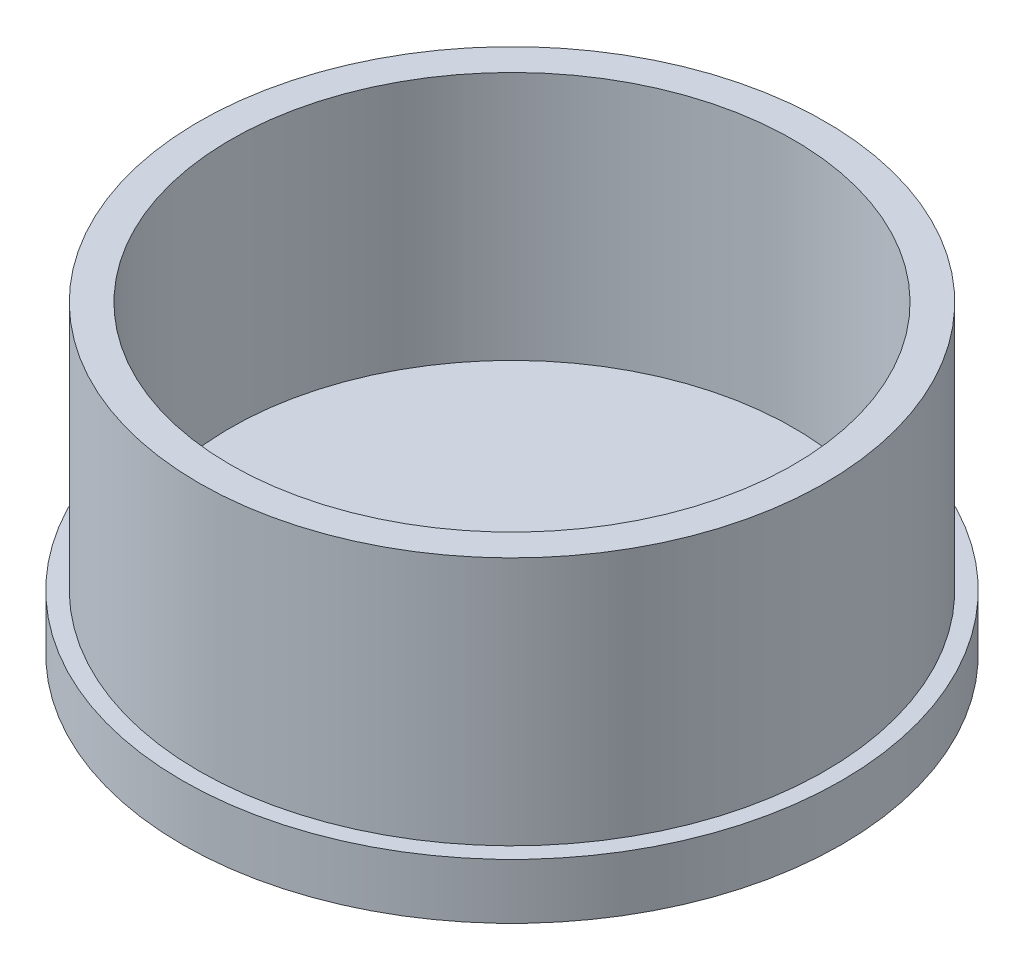
from build123d import *

# Parameters (mm, degrees)
ESBO_O1_R                = 59.5
RESSALTO_EXTRUS_O1_DEPTH = 55
ESBO_O2_R                = 50.8
CORTE_EXTRUS_O1_DEPTH    = 45
ESBO_O3_R                = 59.5
ESBO_O3_R_2              = 56.5
CORTE_EXTRUS_O2_DEPTH    = 45


with BuildPart() as part:
    # Esboço1 → Ressalto-extrusão1 (new body)
    with BuildSketch(Plane(origin=(0, 0, 0), x_dir=(1, 0, 0), z_dir=(0, 1, 0))):
        Circle(ESBO_O1_R)
    extrude(amount=RESSALTO_EXTRUS_O1_DEPTH)

    # Esboço2 → Corte-extrusão1 (cut)
    with BuildSketch(Plane(origin=(0, 55, 0), x_dir=(1, 0, 0), z_dir=(0, 1, 0))):
        Circle(ESBO_O2_R)
    extrude(amount=-CORTE_EXTRUS_O1_DEPTH, mode=Mode.SUBTRACT)

    # Esboço3 → Corte-extrusão2 (cut)
    with BuildSketch(Plane(origin=(0, 55, 0), x_dir=(1, 0, 0), z_dir=(0, 1, 0))):
        Circle(ESBO_O3_R)
        Circle(ESBO_O3_R_2, mode=Mode.SUBTRACT)
    extrude(amount=-CORTE_EXTRUS_O2_DEPTH, mode=Mode.SUBTRACT)


solid = part.part
